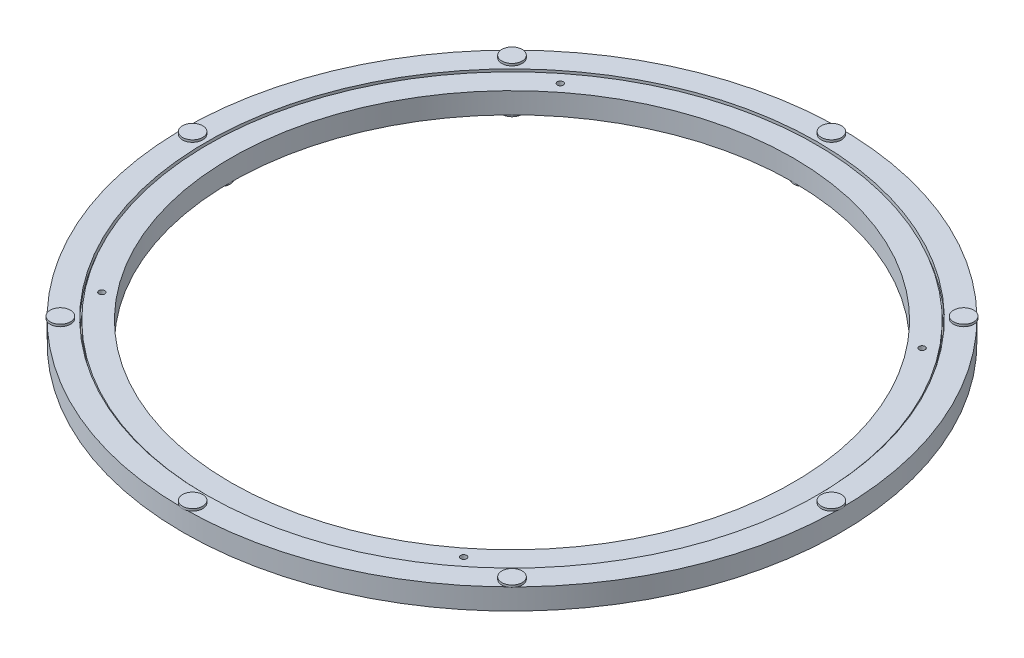
from build123d import *

# Parameters (mm, degrees)
SKETCH6_R          = 2
CUT_EXTRUDE2_DEPTH = 8.55
CIRPATTERN1_COUNT  = 4
SKETCH7_R          = 3.05
CUT_EXTRUDE3_DEPTH = 6.5
CIRPATTERN2_COUNT  = 8
SKETCH8_R          = 3.05
CUT_EXTRUDE4_DEPTH = 6.5
CIRPATTERN3_COUNT  = 8
CIRPATTERN4_COUNT  = 8
CIRPATTERN5_COUNT  = 8


with BuildPart() as part:
    # Sketch4 → Revolve1 (revolve)
    with BuildSketch(Plane(origin=(0, 0, 0), x_dir=(0, 0, -1), z_dir=(1, 0, 0))):
        with BuildLine():
            Line((204.5, 6.55), (204.5, 3.937127959))
            ThreePointArc((204.5, 3.937127959), (201.03125, 0), (204.5, -3.937127959))
            Line((204.5, -3.937127959), (204.5, -7.55))
            Line((204.5, -7.55), (189, -7.55))
            Line((189, -7.55), (189, 6.55))
            Line((189, 6.55), (204.5, 6.55))
        make_face()
        with BuildLine():
            Line((221, -6.55), (221, 7.55))
            Line((221, 7.55), (205.5, 7.55))
            Line((205.5, 7.55), (205.5, 3.937127959))
            ThreePointArc((205.5, 3.937127959), (208.96875, 0), (205.5, -3.937127959))
            Line((205.5, -3.937127959), (205.5, -6.55))
            Line((205.5, -6.55), (221, -6.55))
        make_face()
    revolve(axis=Axis((0, 7.55, 0), (0, -1, 0)))

    # Sketch6 → Cut-Extrude2 (cut, symmetric)
    with BuildSketch(Plane(origin=(0, 0, 0), x_dir=(1, 0, 0), z_dir=(0, 1, 0))):
        with Locations((154.087809479, 121.616762702)):
            Circle(SKETCH6_R)
    cut_extrude2 = extrude(amount=CUT_EXTRUDE2_DEPTH, both=True, mode=Mode.SUBTRACT)

    # CirPattern1: Cut-Extrude2 ×4 about axis
    cirpattern1_axis = Axis((0, 0, 0), (0, 1, 0))
    for i in range(1, CIRPATTERN1_COUNT):
        add(cut_extrude2.rotate(cirpattern1_axis, i * 360 / CIRPATTERN1_COUNT), mode=Mode.SUBTRACT)

    # Sketch7 → Cut-Extrude3 (cut)
    with BuildSketch(Plane(origin=(0, 7.55, 0), x_dir=(1, 0, 0), z_dir=(0, 1, 0))):
        with Locations((0, 214.699999987)):
            Circle(SKETCH7_R)
    cut_extrude3 = extrude(amount=-CUT_EXTRUDE3_DEPTH, mode=Mode.SUBTRACT)

    # CirPattern2: Cut-Extrude3 ×8 about axis
    cirpattern2_axis = Axis((0, 0, 0), (0, 1, 0))
    for i in range(1, CIRPATTERN2_COUNT):
        add(cut_extrude3.rotate(cirpattern2_axis, i * 360 / CIRPATTERN2_COUNT), mode=Mode.SUBTRACT)

    # Sketch8 → Cut-Extrude4 (cut)
    with BuildSketch(Plane(origin=(0, -7.55, 0), x_dir=(1, 0, 0), z_dir=(0, 1, 0))):
        with Locations((0, 196.3)):
            Circle(SKETCH8_R)
    cut_extrude4 = extrude(amount=CUT_EXTRUDE4_DEPTH, mode=Mode.SUBTRACT)

    # CirPattern3: Cut-Extrude4 ×8 about axis
    cirpattern3_axis = Axis((0, 0, 0), (0, 1, 0))
    for i in range(1, CIRPATTERN3_COUNT):
        add(cut_extrude4.rotate(cirpattern3_axis, i * 360 / CIRPATTERN3_COUNT), mode=Mode.SUBTRACT)


with BuildPart() as body_2:
    # Sketch9 → Revolve2 (revolve)
    with BuildSketch(Plane(origin=(0, 0, 0), x_dir=(0, 0, -1), z_dir=(1, 0, 0))):
        Polygon((214.699999987, 1.05), (214.699999987, 9.017), (221.499999987, 9.017), (221.499999987, 7.55), (217.749999987, 7.55), (217.749999987, 1.05), align=None)
    revolve(axis=Axis((0, -6.55, -214.699999987), (0, 1, 0)))


with BuildPart() as cirpattern4_1:
    # CirPattern4: pattern copy
    add(body_2.part.rotate(Axis((0, 0, 0), (0, 1, 0)), 1 * 360 / CIRPATTERN4_COUNT))


with BuildPart() as cirpattern4_2:
    # CirPattern4: pattern copy
    add(body_2.part.rotate(Axis((0, 0, 0), (0, 1, 0)), 2 * 360 / CIRPATTERN4_COUNT))


with BuildPart() as cirpattern4_3:
    # CirPattern4: pattern copy
    add(body_2.part.rotate(Axis((0, 0, 0), (0, 1, 0)), 3 * 360 / CIRPATTERN4_COUNT))


with BuildPart() as cirpattern4_4:
    # CirPattern4: pattern copy
    add(body_2.part.rotate(Axis((0, 0, 0), (0, 1, 0)), 4 * 360 / CIRPATTERN4_COUNT))


with BuildPart() as cirpattern4_5:
    # CirPattern4: pattern copy
    add(body_2.part.rotate(Axis((0, 0, 0), (0, 1, 0)), 5 * 360 / CIRPATTERN4_COUNT))


with BuildPart() as cirpattern4_6:
    # CirPattern4: pattern copy
    add(body_2.part.rotate(Axis((0, 0, 0), (0, 1, 0)), 6 * 360 / CIRPATTERN4_COUNT))


with BuildPart() as cirpattern4_7:
    # CirPattern4: pattern copy
    add(body_2.part.rotate(Axis((0, 0, 0), (0, 1, 0)), 7 * 360 / CIRPATTERN4_COUNT))


with BuildPart() as body_10:
    # Sketch10 → Revolve3 (revolve)
    with BuildSketch(Plane(origin=(0, 0, 0), x_dir=(0, 0, -1), z_dir=(1, 0, 0))):
        Polygon((193.25, -7.55), (189.5, -7.55), (189.5, -9.017), (196.3, -9.017), (196.3, -1.05), (193.25, -1.05), align=None)
    revolve(axis=Axis((0, 6.55, -196.3), (0, -1, 0)))


with BuildPart() as cirpattern5_1:
    # CirPattern5: pattern copy
    add(body_10.part.rotate(Axis((0, 0, 0), (0, 1, 0)), 1 * 360 / CIRPATTERN5_COUNT))


with BuildPart() as cirpattern5_2:
    # CirPattern5: pattern copy
    add(body_10.part.rotate(Axis((0, 0, 0), (0, 1, 0)), 2 * 360 / CIRPATTERN5_COUNT))


with BuildPart() as cirpattern5_3:
    # CirPattern5: pattern copy
    add(body_10.part.rotate(Axis((0, 0, 0), (0, 1, 0)), 3 * 360 / CIRPATTERN5_COUNT))


with BuildPart() as cirpattern5_4:
    # CirPattern5: pattern copy
    add(body_10.part.rotate(Axis((0, 0, 0), (0, 1, 0)), 4 * 360 / CIRPATTERN5_COUNT))


with BuildPart() as cirpattern5_5:
    # CirPattern5: pattern copy
    add(body_10.part.rotate(Axis((0, 0, 0), (0, 1, 0)), 5 * 360 / CIRPATTERN5_COUNT))


with BuildPart() as cirpattern5_6:
    # CirPattern5: pattern copy
    add(body_10.part.rotate(Axis((0, 0, 0), (0, 1, 0)), 6 * 360 / CIRPATTERN5_COUNT))


with BuildPart() as cirpattern5_7:
    # CirPattern5: pattern copy
    add(body_10.part.rotate(Axis((0, 0, 0), (0, 1, 0)), 7 * 360 / CIRPATTERN5_COUNT))


solid = Compound([part.part, body_2.part, cirpattern4_1.part, cirpattern4_2.part, cirpattern4_3.part, cirpattern4_4.part, cirpattern4_5.part, cirpattern4_6.part, cirpattern4_7.part, body_10.part, cirpattern5_1.part, cirpattern5_2.part, cirpattern5_3.part, cirpattern5_4.part, cirpattern5_5.part, cirpattern5_6.part, cirpattern5_7.part])
